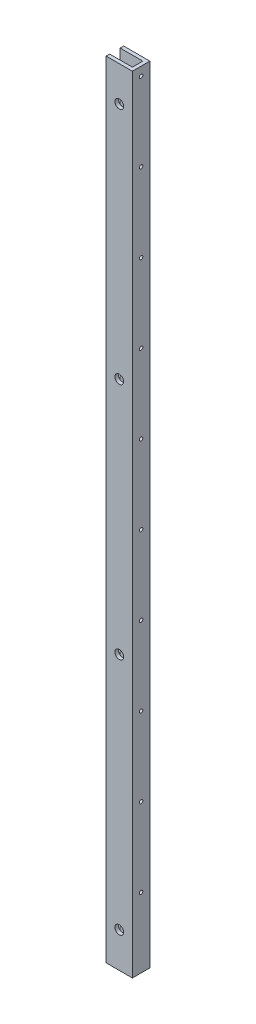
from build123d import *

# Parameters (mm, degrees)
BOSS_EXTRUDE1_DEPTH = 285.75
SKETCH2_R           = 1.27
CUT_EXTRUDE1_DEPTH  = 20.05
SKETCH4_R           = 3.175
CUT_EXTRUDE2_DEPTH  = 140.208
SKETCH5_R           = 6.35
CUT_EXTRUDE3_DEPTH  = 2.54


with BuildPart() as part:
    # Sketch1 → Boss-Extrude1 (new body, symmetric)
    with BuildSketch(Plane(origin=(0, 0, 0), x_dir=(1, 0, 0), z_dir=(0, 1, 0))):
        Polygon((-19.05, 3.81), (-19.05, 6.35), (0, 6.35), (0, -6.35), (-19.05, -6.35), (-19.05, -3.81), (-2.54, -3.81), (-2.54, 3.81), align=None)
    extrude(amount=BOSS_EXTRUDE1_DEPTH, both=True)

    # Sketch2 → Cut-Extrude1 (cut, through all)
    with BuildSketch(Plane(origin=(0, 0, 0), x_dir=(0, 0, -1), z_dir=(1, 0, 0))):
        with Locations((0, 279.4)):
            Circle(SKETCH2_R)
        with Locations((0, 222.25)):
            Circle(SKETCH2_R)
        with Locations((0, 165.1)):
            Circle(SKETCH2_R)
        with Locations((0, 107.95)):
            Circle(SKETCH2_R)
        with Locations((0, 50.8)):
            Circle(SKETCH2_R)
        with Locations((0, -6.35)):
            Circle(SKETCH2_R)
        with Locations((0, -63.5)):
            Circle(SKETCH2_R)
        with Locations((0, -120.65)):
            Circle(SKETCH2_R)
        with Locations((0, -177.8)):
            Circle(SKETCH2_R)
        with Locations((0, -234.95)):
            Circle(SKETCH2_R)
    extrude(amount=-CUT_EXTRUDE1_DEPTH, mode=Mode.SUBTRACT)

    # Sketch4 → Cut-Extrude2 (cut)
    with BuildSketch(Plane(origin=(0, 0, 3.81), x_dir=(-1, 0, 0), z_dir=(0, 0, -1))):
        with Locations((9.525, 260.35)):
            Circle(SKETCH4_R)
        with Locations((9.525, 86.868)):
            Circle(SKETCH4_R)
        with Locations((9.525, -86.614)):
            Circle(SKETCH4_R)
        with Locations((9.525, -260.096)):
            Circle(SKETCH4_R)
    extrude(amount=-CUT_EXTRUDE2_DEPTH, mode=Mode.SUBTRACT)

    # Sketch5 → Cut-Extrude3 (cut)
    with BuildSketch(Plane(origin=(0, 0, -6.35), x_dir=(-1, 0, 0), z_dir=(0, 0, -1))):
        with Locations((9.525, 260.35)):
            Circle(SKETCH5_R)
        with Locations((9.525, 86.7918)):
            Circle(SKETCH5_R)
        with Locations((9.525, -86.7664)):
            Circle(SKETCH5_R)
        with Locations((9.525, -260.3246)):
            Circle(SKETCH5_R)
    extrude(amount=-CUT_EXTRUDE3_DEPTH, mode=Mode.SUBTRACT)


solid = part.part
